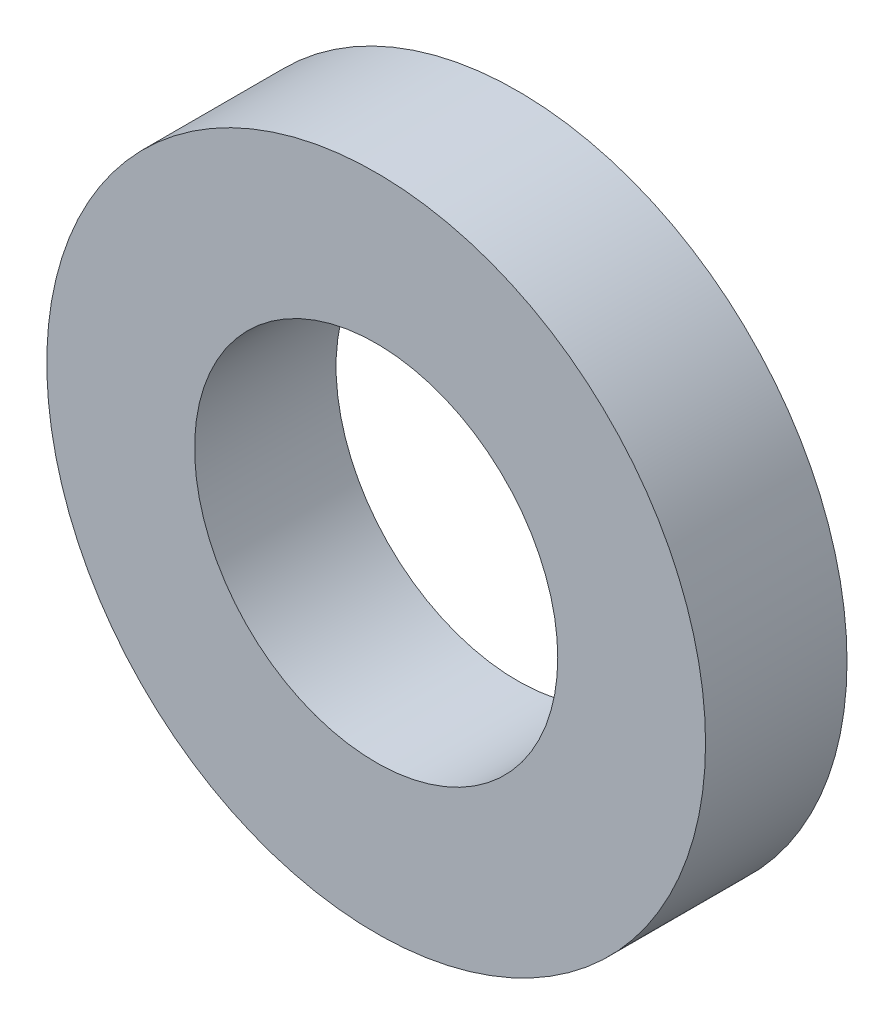
from build123d import *

# Parameters (mm, degrees)
SKETCH1_R      = 3.9624
SKETCH1_R_2    = 2.1844
EXTRUDE1_DEPTH = 1.7018


with BuildPart() as part:
    # Sketch1 → Extrude1 (new body)
    with BuildSketch(Plane.XY):
        Circle(SKETCH1_R)
        Circle(SKETCH1_R_2, mode=Mode.SUBTRACT)
    extrude(amount=-EXTRUDE1_DEPTH)


solid = part.part
